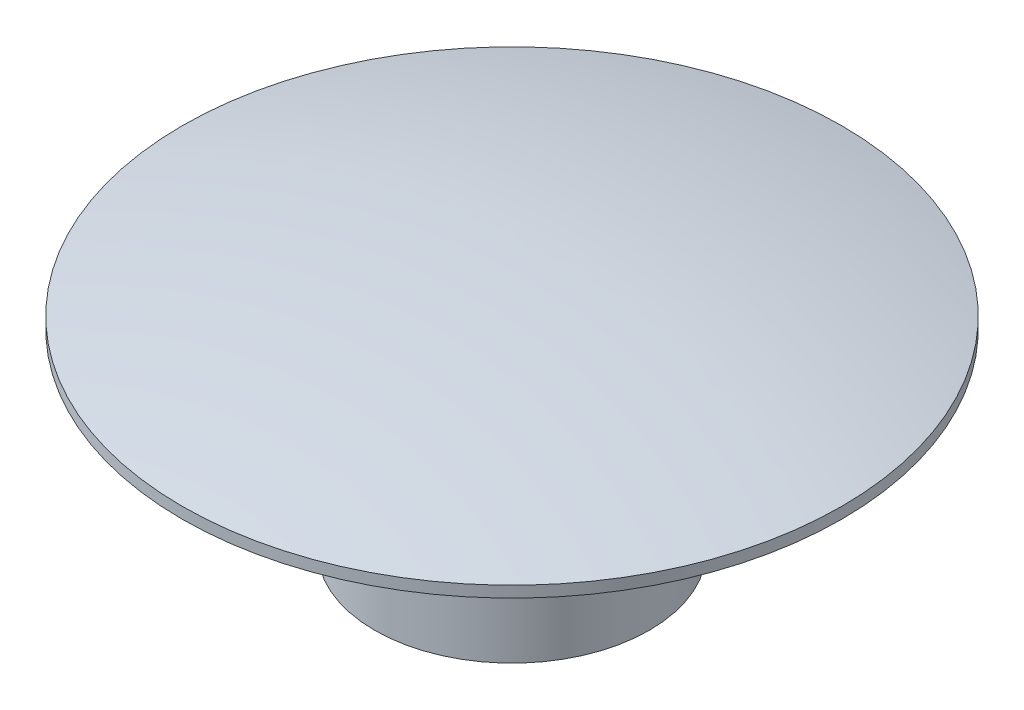
from build123d import *


with BuildPart() as part:
    # Esquisse1 → Révolution1 (revolve)
    with BuildSketch(Plane.XY, mode=Mode.PRIVATE) as r_volution1_sk:
        with BuildLine():
            Line((0, 1), (0, -3.5))
            Line((0, -3.5), (-2.5, -3.5))
            Line((-2.5, -3.5), (-2.5, 0))
            Line((-2.5, 0), (-6, 0))
            Line((-6, 0), (-6, 0.203603311))
            ThreePointArc((-6, 0.203603311), (-3.026311604, 0.800031537), (0, 1))
        make_face()
    revolve(r_volution1_sk.sketch.rotate(Axis((0, -17.325308642, 0), (0, 1, 0)), 270), axis=Axis((0, -17.325308642, 0), (0, 1, 0)))  # turned: the seam where the file's is


solid = part.part
